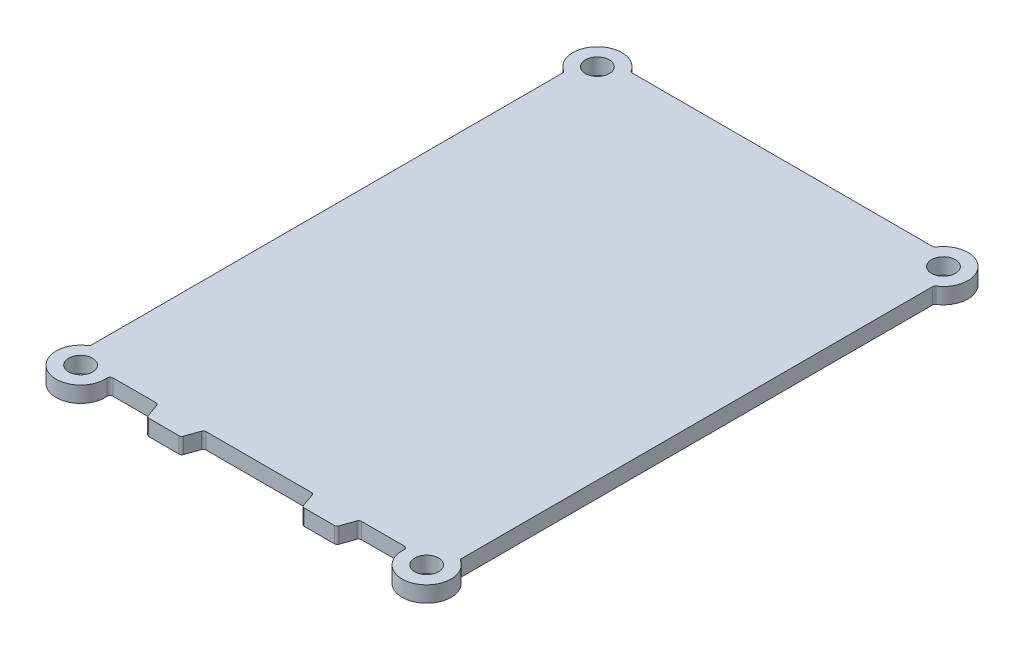
from build123d import *

# Parameters (mm, degrees)
SKETCH1_R           = 2.1
BOSS_EXTRUDE1_DEPTH = 2.8
CUT_EXTRUDE1_REACH  = 4.8
FILLET1_R           = 0.5


with BuildPart() as part:
    # Sketch1 → Boss-Extrude1 (new body)
    with BuildSketch(Plane(origin=(0, 0, 0), x_dir=(1, 0, 0), z_dir=(0, 1, 0))):
        with BuildLine():
            Line((0, 83.295334784), (0, 0))
            ThreePointArc((0, 0), (-0.940559159, -6.792891767), (5.852332608, -5.852332608))
            Line((5.852332608, -5.852332608), (59.147667392, -5.852332608))
            ThreePointArc((59.147667392, -5.852332608), (65.940559159, -6.792891767), (65, 0))
            Line((65, 0), (65, 83.295334784))
            ThreePointArc((65, 83.295334784), (65.940559159, 90.088226551), (59.147667392, 89.147667392))
            Line((59.147667392, 89.147667392), (5.852332608, 89.147667392))
            ThreePointArc((5.852332608, 89.147667392), (-0.940559159, 90.088226551), (0, 83.295334784))
        make_face()
        with Locations((2.1, 87.047667392)):
            Circle(SKETCH1_R, mode=Mode.SUBTRACT)
        with Locations((2.1, -3.752332608)):
            Circle(SKETCH1_R, mode=Mode.SUBTRACT)
        with Locations((62.9, -3.752332608)):
            Circle(SKETCH1_R, mode=Mode.SUBTRACT)
        with Locations((62.9, 87.047667392)):
            Circle(SKETCH1_R, mode=Mode.SUBTRACT)
    extrude(amount=BOSS_EXTRUDE1_DEPTH)

    # Sketch2 → Cut-Extrude1 (cut, up to next)
    with BuildSketch(Plane(origin=(0, 2.8, 0), x_dir=(1, 0, 0), z_dir=(0, 1, 0)), mode=Mode.PRIVATE) as cut_extrude1_sk1:
        Polygon((22.9, -2.852332608), (21.852379604, -5.852332608), (43.147620396, -5.852332608), (42.1, -2.852332608), align=None)
    cut_extrude1_tool1 = extrude(cut_extrude1_sk1.sketch, amount=-CUT_EXTRUDE1_REACH, mode=Mode.PRIVATE) & part.part
    add(cut_extrude1_tool1.solids().sort_by_distance((32.5, 2.8, 4.378203))[0], mode=Mode.SUBTRACT)
    # Sketch2 → Cut-Extrude1 (cut, up to next)
    with BuildSketch(Plane(origin=(0, 2.8, 0), x_dir=(1, 0, 0), z_dir=(0, 1, 0)), mode=Mode.PRIVATE) as cut_extrude1_sk2:
        with BuildLine():
            Line((15.852379604, -5.852332608), (14.804759208, -2.852332608))
            Line((14.804759208, -2.852332608), (6.304759208, -2.852332608))
            ThreePointArc((6.304759208, -2.852332608), (6.351920453, -4.393559913), (5.852332608, -5.852332608))
            Line((5.852332608, -5.852332608), (15.852379604, -5.852332608))
        make_face()
    cut_extrude1_tool2 = extrude(cut_extrude1_sk2.sketch, amount=-CUT_EXTRUDE1_REACH, mode=Mode.PRIVATE) & part.part
    add(cut_extrude1_tool2.solids().sort_by_distance((10.801148, 2.8, 4.393371))[0], mode=Mode.SUBTRACT)
    # Sketch2 → Cut-Extrude1 (cut, up to next)
    with BuildSketch(Plane(origin=(0, 2.8, 0), x_dir=(1, 0, 0), z_dir=(0, 1, 0)), mode=Mode.PRIVATE) as cut_extrude1_sk3:
        with BuildLine():
            Line((59.147667392, -5.852332608), (49.147620396, -5.852332608))
            Line((49.147620396, -5.852332608), (50.195240792, -2.852332608))
            Line((50.195240792, -2.852332608), (58.695240792, -2.852332608))
            ThreePointArc((58.695240792, -2.852332608), (58.648079547, -4.393559913), (59.147667392, -5.852332608))
        make_face()
    cut_extrude1_tool3 = extrude(cut_extrude1_sk3.sketch, amount=-CUT_EXTRUDE1_REACH, mode=Mode.PRIVATE) & part.part
    add(cut_extrude1_tool3.solids().sort_by_distance((54.198852, 2.8, 4.393371))[0], mode=Mode.SUBTRACT)

    # Fillet1
    fillet1_edges = [part.edges().sort_by_distance(p)[0] for p in [
        (5.852332608, 1.4, -89.147667392),
        (59.147667392, 1.4, -89.147667392),
        (65, 1.4, -83.295334784),
        (65, 1.4, 0),
        (0, 1.4, 0),
        (0, 1.4, -83.295334784),
        (58.695240792, 1.4, 2.852332608),
        (49.147620396, 1.4, 5.852332608),
        (50.195240792, 1.4, 2.852332608),
        (15.852379604, 1.4, 5.852332608),
        (6.304759208, 1.4, 2.852332608),
        (14.804759208, 1.4, 2.852332608),
        (22.9, 1.4, 2.852332608),
        (42.1, 1.4, 2.852332608),
        (43.147620396, 1.4, 5.852332608),
        (21.852379604, 1.4, 5.852332608),
    ]]
    fillet(fillet1_edges, radius=FILLET1_R)


solid = part.part
